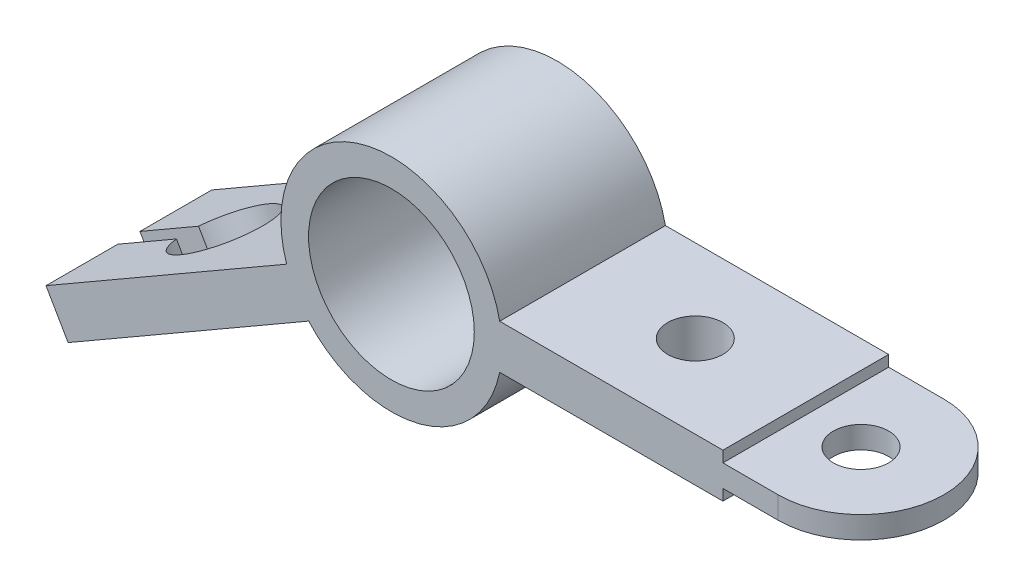
from build123d import *

# Parameters (mm, degrees)
IZIM1_R                     = 50
IZIM1_R_2                   = 37.5
IZIM1_W                     = 25
IZIM1_H                     = 10
Y_KSEKLIK_EKSTR_ZYON1_DEPTH = 37.5
Y_KSEKLIK_EKSTR_ZYON2_DEPTH = 10
IZIM3_R                     = 12.5
KES_EKSTR_ZYON1_DEPTH       = 10
IZIM4_R                     = 12.5
KES_EKSTR_ZYON2_DEPTH       = 107.017280086
KES_EKSTR_ZYON3_DEPTH       = 200.403403757


with BuildPart() as part:
    # Çizim1 → Yükseklik-Ekstrüzyon1 (new body, symmetric)
    with BuildSketch(Plane.XY):
        with BuildLine():
            Line((-156.306807514, -78.69677201), (-146.306807514, -96.017280086))
            Line((-146.306807514, -96.017280086), (-37.426406871, -33.155151466))
            ThreePointArc((-37.426406871, -33.155151466), (-43.301270189, -25), (-47.426406871, -15.83464339))
            Line((-47.426406871, -15.83464339), (-156.306807514, -78.69677201))
        make_face()
        Circle(IZIM1_R)
        Circle(IZIM1_R_2, mode=Mode.SUBTRACT)
        with BuildLine():
            ThreePointArc((50, 0), (49.74680765, -5.0254481), (48.989794856, -10))
            Line((48.989794856, -10), (150, -10))
            Line((150, -10), (150, -5))
            Line((150, -5), (150, 5))
            Line((150, 5), (150, 10))
            Line((150, 10), (48.989794856, 10))
            ThreePointArc((48.989794856, 10), (49.74680765, 5.0254481), (50, 0))
        make_face()
        with Locations((162.5, 0)):
            Rectangle(IZIM1_W, IZIM1_H)
    extrude(amount=Y_KSEKLIK_EKSTR_ZYON1_DEPTH, both=True)

    # Çizim2 → Yükseklik-Ekstrüzyon2 (add)
    with BuildSketch(Plane(origin=(0, 5, 0), x_dir=(1, 0, 0), z_dir=(0, 1, 0))):
        with BuildLine():
            Line((175, 37.5), (175, -37.5))
            ThreePointArc((175, -37.5), (212.5, 0), (175, 37.5))
        make_face()
    extrude(amount=-Y_KSEKLIK_EKSTR_ZYON2_DEPTH)

    # Çizim3 → Kes-Ekstrüzyon1 (cut)
    with BuildSketch(Plane(origin=(0, 5, 0), x_dir=(1, 0, 0), z_dir=(0, 1, 0))):
        with Locations((175, 0)):
            Circle(IZIM3_R)
    extrude(amount=-KES_EKSTR_ZYON1_DEPTH, mode=Mode.SUBTRACT)

    # Çizim4 → Kes-Ekstrüzyon2 (cut, through all)
    with BuildSketch(Plane(origin=(0, 10, 0), x_dir=(1, 0, 0), z_dir=(0, 1, 0))):
        with Locations((100, 0)):
            Circle(IZIM4_R)
    extrude(amount=-KES_EKSTR_ZYON2_DEPTH, mode=Mode.SUBTRACT)

    # Çizim5 → Kes-Ekstrüzyon3 (cut, through all)
    with BuildSketch(Plane(origin=(-5, 8.660254038, 0), x_dir=(0.866025404, 0.5, 0), z_dir=(-0.5, 0.866025404, 0))):
        with BuildLine():
            Line((-174.714052097, 5), (-174.714052097, -5))
            Line((-174.714052097, -5), (-144.078968828, -5))
            ThreePointArc((-144.078968828, -5), (-104.714052097, 0), (-144.078968828, 5))
            Line((-144.078968828, 5), (-174.714052097, 5))
        make_face()
    extrude(amount=-KES_EKSTR_ZYON3_DEPTH, mode=Mode.SUBTRACT)


solid = part.part
